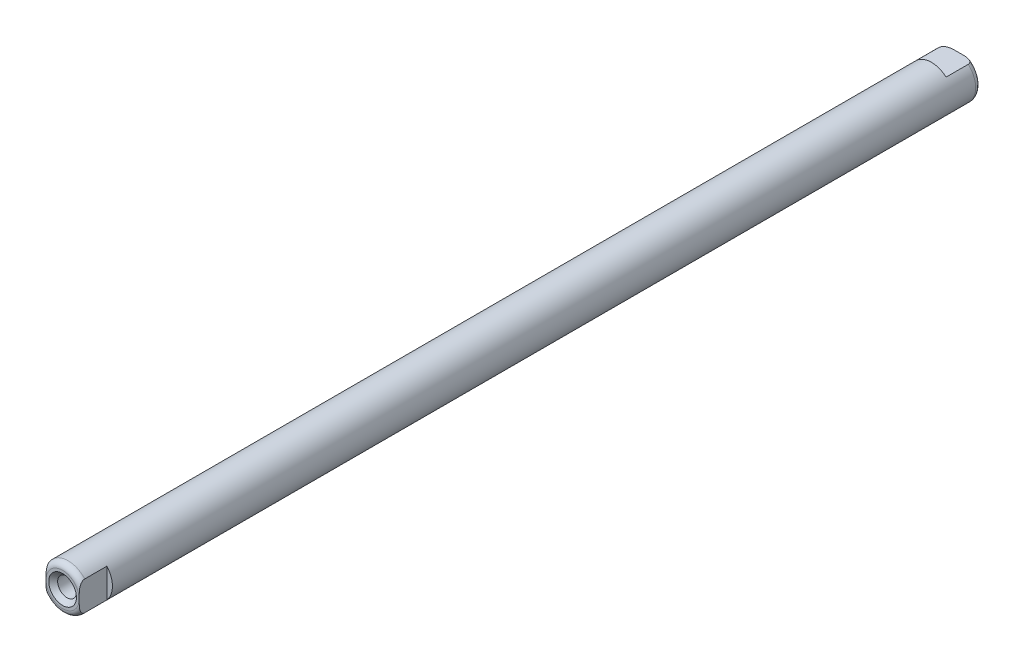
from build123d import *

# Parameters (mm, degrees)
ESQUISSE1_R             = 8
BOSS_EXTRU_1_DEPTH      = 162
CONG_1_R                = 2
ESQUISSE4_OUTSIDE_W     = 82.958
ESQUISSE4_OUTSIDE_H     = 82.958
ESQUISSE4_OUTSIDE_W_2   = 16
ESQUISSE4_OUTSIDE_H_2   = 12
ENL_V_MAT_EXTRU_1_DEPTH = 10
ESQUISSE5_OUTSIDE_W     = 82.958
ESQUISSE5_OUTSIDE_H     = 82.958
ESQUISSE5_OUTSIDE_W_2   = 12
ESQUISSE5_OUTSIDE_H_2   = 16
ENL_V_MAT_EXTRU_2_DEPTH = 10


with BuildPart() as part:
    # Esquisse1 → Boss.-Extru.1 (new body, symmetric)
    with BuildSketch(Plane.XY):
        Circle(ESQUISSE1_R)
    extrude(amount=BOSS_EXTRU_1_DEPTH, both=True)

    # Congé1
    cong_1_edges = [part.edges().sort_by_distance(p)[0] for p in [
        (-8, 0, -162),
        (-8, 0, 162),
    ]]
    fillet(cong_1_edges, radius=CONG_1_R)

    # Esquisse2 → Trou taraudé M81 (revolve, cut)
    with BuildSketch(Plane(origin=(0, 0, -162), x_dir=(0, 1, 0), z_dir=(1, 0, 0))):
        Polygon((0, 0), (0, 24.292926105), (3.4, 22.25), (3.4, 1.6), (5, 0), align=None)
    trou_taraud_m81 = revolve(axis=Axis((0, 0, -168.35), (0, 0, 1)), mode=Mode.SUBTRACT)

    # Symétrie5: Trou taraudé M81 across plane
    add(trou_taraud_m81.mirror(Plane.XY), mode=Mode.SUBTRACT)

    # Esquisse4 outside → Enlèv. mat.-Extru.1 (cut)
    with BuildSketch(Plane(origin=(0, 0, -162), x_dir=(-1, 0, 0), z_dir=(0, 0, -1))):
        Rectangle(ESQUISSE4_OUTSIDE_W, ESQUISSE4_OUTSIDE_H)
        Rectangle(ESQUISSE4_OUTSIDE_W_2, ESQUISSE4_OUTSIDE_H_2, mode=Mode.SUBTRACT)
    extrude(amount=-ENL_V_MAT_EXTRU_1_DEPTH, mode=Mode.SUBTRACT)

    # Esquisse5 outside → Enlèv. mat.-Extru.2 (cut)
    with BuildSketch(Plane.XY.offset(162)):
        Rectangle(ESQUISSE5_OUTSIDE_W, ESQUISSE5_OUTSIDE_H)
        Rectangle(ESQUISSE5_OUTSIDE_W_2, ESQUISSE5_OUTSIDE_H_2, mode=Mode.SUBTRACT)
    extrude(amount=-ENL_V_MAT_EXTRU_2_DEPTH, mode=Mode.SUBTRACT)


solid = part.part
